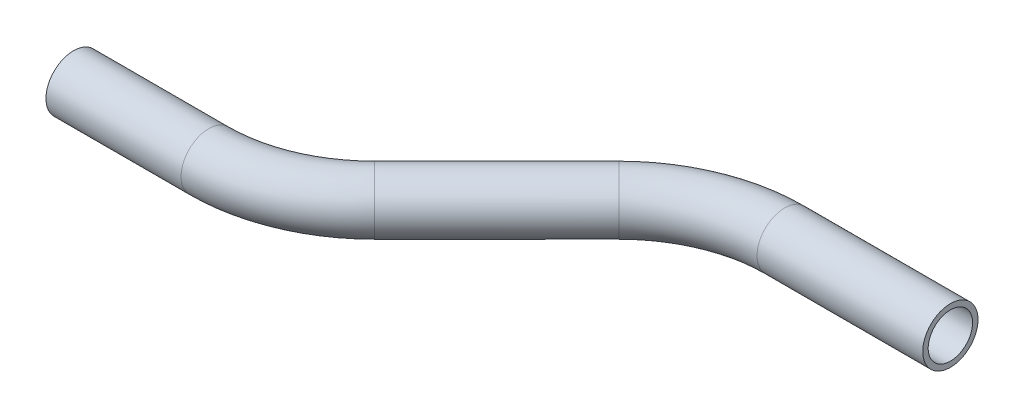
from build123d import *

# Parameters (mm, degrees)
SKETCH2_R   = 6.35
SKETCH2_R_2 = 5.1054


with BuildPart() as part:
    # Sweep1: sweep along a path in Sketch1
    with BuildLine(Plane(origin=(0, 0, 0), x_dir=(1, 0, 0), z_dir=(0, 1, 0))) as sweep1_path:
        Line((0, 0), (31.066352514, 0))
        ThreePointArc((31.066352514, 0), (45.646591287, 2.900189811), (58.007120878, 11.159231637))
        Line((58.007120878, 11.159231637), (86.104787404, 39.256898163))
        ThreePointArc((86.104787404, 39.256898163), (98.465316994, 47.515939989), (113.045555767, 50.4161298))
        Line((113.045555767, 50.4161298), (151.145555767, 50.4161298))
    # Sketch2 → Sweep1 (sweep)
    with BuildSketch(Plane(origin=(0, 0, 0), x_dir=(0, 0, -1), z_dir=(1, 0, 0))):
        Circle(SKETCH2_R)
        Circle(SKETCH2_R_2, mode=Mode.SUBTRACT)
    sweep(path=sweep1_path.line)


solid = part.part
